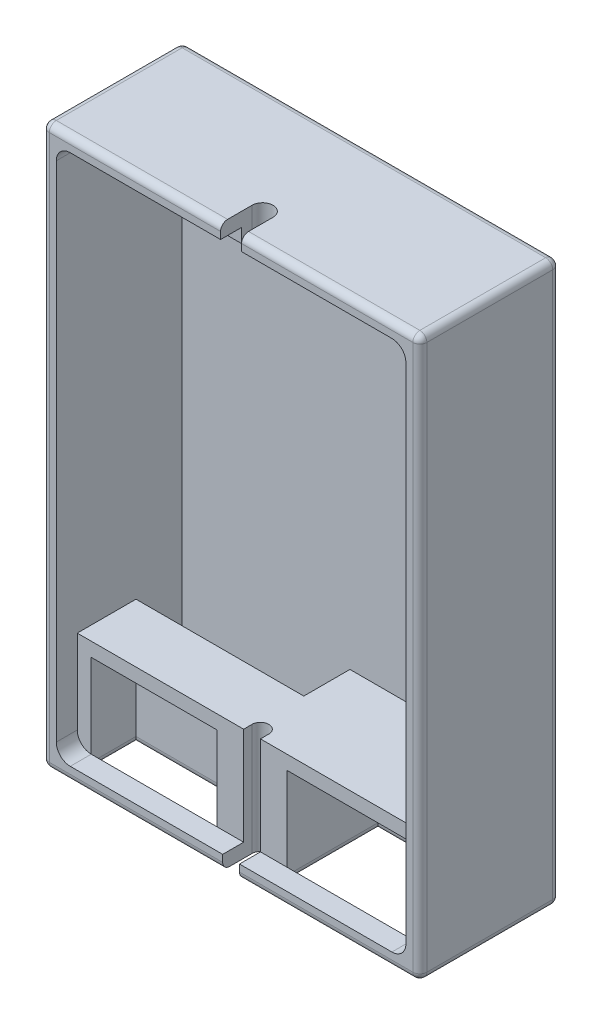
from build123d import *

# Parameters (mm, degrees)
SKETCH_2_W           = 27
SKETCH_2_H           = 40
EXTRUDE_1_DEPTH      = 10
CUT_EXTRUDE_1_DEPTH  = 1.5
CUT_EXTRUDE_2_DEPTH  = 7.5
SKETCH_9_W           = 9
SKETCH_9_H           = 4.718038217
CUT_EXTRUDE_8_DEPTH  = 6.5
SKETCH_9_3_W         = 9
SKETCH_9_3_H         = 4.718038217
CUT_EXTRUDE_9_DEPTH  = 3.2
SKETCH_13_W          = 9
SKETCH_13_H          = 3.2
SKETCH_13_H_2        = 6.5
CUT_EXTRUDE_11_DEPTH = 3.281961783
CUT_EXTRUDE_12_REACH = 42
SKETCH_14_W          = 1.2
SKETCH_14_H          = 2.1
SKETCH_16_2_W        = 7
SKETCH_16_2_H        = 2.5
EXTRUDE_3_DEPTH      = 1
SKETCH_16_W          = 7
SKETCH_16_H          = 2.5
EXTRUDE_2_DEPTH      = 1
CUT_EXTRUDE_14_DEPTH = 2
FILLET_1_R           = 0.5
SKETCH_18_W          = 12
SKETCH_18_H          = 3.3
CUT_EXTRUDE_15_DEPTH = 7


with BuildPart() as part:
    # Sketch 2 → Extrude 1 (new body)
    with BuildSketch(Plane.XY):
        with Locations((13.5, 20)):
            Rectangle(SKETCH_2_W, SKETCH_2_H)
    extrude(amount=EXTRUDE_1_DEPTH)

    # Sketch 3 → Cut-Extrude 1 (cut)
    with BuildSketch(Plane.XY.offset(10)):
        with BuildLine():
            Line((1, 38), (1, 2))
            ThreePointArc((1, 2), (1.292893219, 1.292893219), (2, 1))
            Line((2, 1), (25, 1))
            ThreePointArc((25, 1), (25.707106781, 1.292893219), (26, 2))
            Line((26, 2), (26, 38))
            ThreePointArc((26, 38), (25.707106781, 38.707106781), (25, 39))
            Line((25, 39), (2, 39))
            ThreePointArc((2, 39), (1.292893219, 38.707106781), (1, 38))
        make_face()
    extrude(amount=-CUT_EXTRUDE_1_DEPTH, mode=Mode.SUBTRACT)

    # Sketch 5 → Cut-Extrude 2 (cut)
    with BuildSketch(Plane.XY.offset(8.5)):
        with BuildLine():
            Line((2, 39), (25, 39))
            ThreePointArc((25, 39), (25.707106781, 38.707106781), (26, 38))
            Line((26, 38), (26, 8))
            Line((26, 8), (1, 8))
            Line((1, 8), (1, 38))
            ThreePointArc((1, 38), (1.292893219, 38.707106781), (2, 39))
        make_face()
    extrude(amount=-CUT_EXTRUDE_2_DEPTH, mode=Mode.SUBTRACT)

    # Sketch 9 → Cut-Extrude 8 (cut)
    with BuildSketch(Plane.XY.offset(8.5)):
        with Locations((20.5, 4.640980891)):
            Rectangle(SKETCH_9_W, SKETCH_9_H)
    extrude(amount=-CUT_EXTRUDE_8_DEPTH, mode=Mode.SUBTRACT)

    # Sketch 9_3 → Cut-Extrude 9 (cut)
    with BuildSketch(Plane.XY.offset(8.5)):
        with Locations((6.5, 4.640980891)):
            Rectangle(SKETCH_9_3_W, SKETCH_9_3_H)
    extrude(amount=-CUT_EXTRUDE_9_DEPTH, mode=Mode.SUBTRACT)

    # Sketch 13 → Cut-Extrude 11 (cut, through all)
    with BuildSketch(Plane(origin=(0, 2.281961783, 0), x_dir=(1, 0, 0), z_dir=(0, 1, 0))):
        with Locations((6.5, -6.9)):
            Rectangle(SKETCH_13_W, SKETCH_13_H)
        with Locations((20.5, -5.25)):
            Rectangle(SKETCH_13_W, SKETCH_13_H_2)
    extrude(amount=-CUT_EXTRUDE_11_DEPTH, mode=Mode.SUBTRACT)

    # Sketch 14 → Cut-Extrude 12 (cut, up to next)
    with BuildSketch(Plane.XZ, mode=Mode.PRIVATE) as cut_extrude_12_sk1:
        with BuildLine():
            Line((12.9, 7.9), (14.1, 7.9))
            ThreePointArc((14.1, 7.9), (13.5, 7.3), (12.9, 7.9))
        make_face()
    cut_extrude_12_tool1 = extrude(cut_extrude_12_sk1.sketch, amount=-CUT_EXTRUDE_12_REACH, mode=Mode.PRIVATE) & part.part
    add(cut_extrude_12_tool1.solids().sort_by_distance((13.5, 0, 7.645352))[0], mode=Mode.SUBTRACT)
    # Sketch 14 → Cut-Extrude 12 (cut, up to next)
    with BuildSketch(Plane.XZ, mode=Mode.PRIVATE) as cut_extrude_12_sk2:
        with Locations((13.5, 8.95)):
            Rectangle(SKETCH_14_W, SKETCH_14_H)
    cut_extrude_12_tool2 = extrude(cut_extrude_12_sk2.sketch, amount=-CUT_EXTRUDE_12_REACH, mode=Mode.PRIVATE) & part.part
    add(cut_extrude_12_tool2.solids().sort_by_distance((13.5, 0, 8.95))[0], mode=Mode.SUBTRACT)

    # Sketch 16_2 → Extrude 3 (add)
    with BuildSketch(Plane.XZ.offset(-39)):
        with Locations((13.5, 7.25)):
            Rectangle(SKETCH_16_2_W, SKETCH_16_2_H)
    extrude(amount=EXTRUDE_3_DEPTH)

    # Sketch 16 → Extrude 2 (add)
    with BuildSketch(Plane.XZ.offset(-39)):
        with Locations((13.5, 7.25)):
            Rectangle(SKETCH_16_W, SKETCH_16_H)
    extrude(amount=EXTRUDE_2_DEPTH)

    # Sketch 17 → Cut-Extrude 14 (cut)
    with BuildSketch(Plane(origin=(0, 40, 0), x_dir=(1, 0, 0), z_dir=(0, 1, 0))):
        with BuildLine():
            Line((14.25, -7.75), (14.25, -10))
            Line((14.25, -10), (12.75, -10))
            Line((12.75, -10), (12.75, -7.75))
            ThreePointArc((12.75, -7.75), (13.5, -7), (14.25, -7.75))
        make_face()
    extrude(amount=-CUT_EXTRUDE_14_DEPTH, mode=Mode.SUBTRACT)

    # Fillet 1
    fillet_1_edges = [part.edges().sort_by_distance(p)[0] for p in [
        (27, 20, 10),
        (20.55, 0, 10),
        (20.625, 40, 10),
        (6.375, 40, 10),
        (0, 20, 10),
        (13.5, 40, 0),
        (27, 20, 0),
        (13.5, 0, 0),
        (0, 20, 0),
        (6.45, 0, 10),
        (0, 40, 5),
        (27, 40, 5),
        (27, 0, 5),
        (0, 0, 5),
        (6.5, 0, 8.5),
        (11, 0, 6.9),
        (2, 0, 6.9),
        (6.5, 0, 5.3),
        (20.5, 0, 8.5),
        (25, 0, 5.25),
        (16, 0, 5.25),
        (20.5, 0, 2),
    ]]
    fillet(fillet_1_edges, radius=FILLET_1_R)

    # Sketch 18 → Cut-Extrude 15 (cut)
    with BuildSketch(Plane(origin=(0, 8, 0), x_dir=(1, 0, 0), z_dir=(0, 1, 0))):
        with Locations((7, -2.65)):
            Rectangle(SKETCH_18_W, SKETCH_18_H)
    extrude(amount=-CUT_EXTRUDE_15_DEPTH, mode=Mode.SUBTRACT)


solid = part.part
